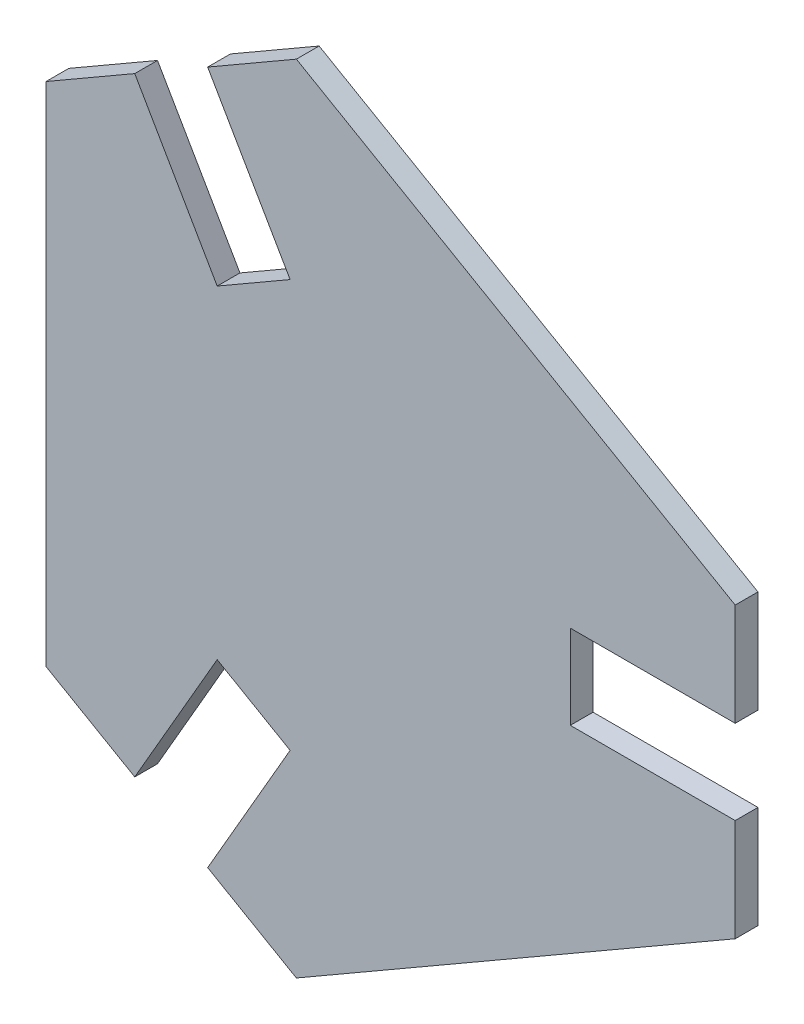
from build123d import *

# Parameters (mm, degrees)
SALIENTE_EXTRUIR1_DEPTH = 5


with BuildPart() as part:
    # Croquis1 → Saliente-Extruir1 (new body)
    with BuildSketch(Plane.XY):
        Polygon((82.6, -9.25), (46.375772068, -9.25), (46.375772068, 9.25), (82.6, 9.25), (82.6, 31.75), (-13.80369343, 87.408698353), (-33.289265015, 76.158698353), (-15.177151049, 44.787596731), (-31.198621019, 35.537596731), (-49.310734985, 66.908698353), (-68.79630657, 55.658698353), (-68.79630657, -55.658698353), (-49.310734985, -66.908698353), (-31.198621019, -35.537596731), (-15.177151049, -44.787596731), (-33.289265015, -76.158698353), (-13.80369343, -87.408698353), (82.6, -31.75), align=None)
    extrude(amount=SALIENTE_EXTRUIR1_DEPTH)


solid = part.part
